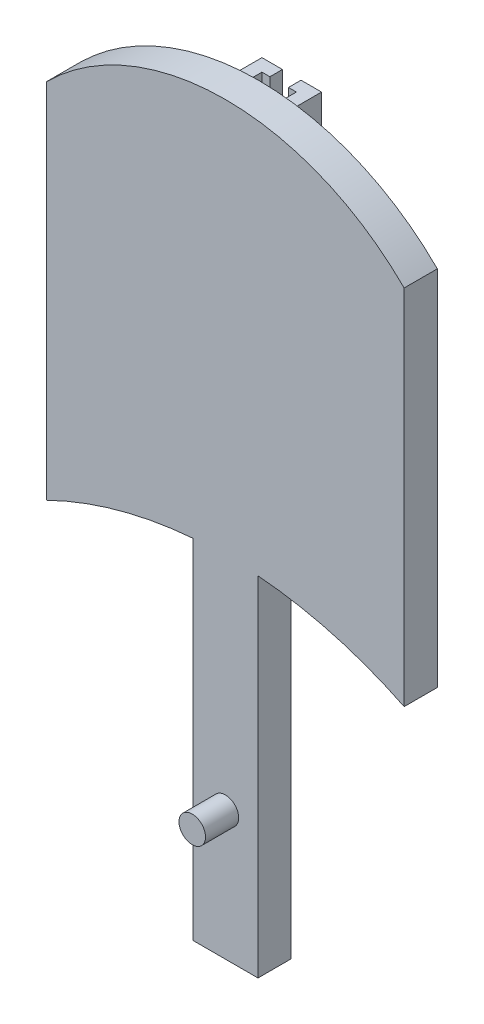
from build123d import *

# Parameters (mm, degrees)
BOSS_EXTRUDE1_DEPTH = 3.175
BOSS_EXTRUDE2_DEPTH = 3.175
SKETCH3_W           = 6.236959702
SKETCH3_H           = 47.194711522
BOSS_EXTRUDE3_DEPTH = 3.175
SKETCH4_R           = 1.27
BOSS_EXTRUDE4_DEPTH = 3.175
BOSS_EXTRUDE5_REACH = 20.766
SKETCH6_W           = 1.202138058
SKETCH6_H           = 36.716281243
CUT_EXTRUDE1_REACH  = 11.525


with BuildPart() as part:
    # Sketch1 → Boss-Extrude1 (new body)
    with BuildSketch(Plane.XY):
        with BuildLine():
            Line((-17.114253333, -17.357583949), (-17.114253333, 17.357583949))
            ThreePointArc((-17.114253333, 17.357583949), (0, 24.432200125), (17.114253333, 17.357583949))
            Line((17.114253333, 17.357583949), (17.114253333, -17.357583949))
            ThreePointArc((17.114253333, -17.357583949), (0, -13.382802691), (-17.114253333, -17.357583949))
        make_face()
    extrude(amount=BOSS_EXTRUDE1_DEPTH)

    # Sketch2 → Boss-Extrude2 (add)
    with BuildSketch(Plane(origin=(0, 0, 0), x_dir=(-1, 0, 0), z_dir=(0, 0, -1))):
        with BuildLine():
            Line((-1.65128862, -13.417928303), (-1.65128862, 22.268343179))
            Line((-1.65128862, 22.268343179), (-1.65128862, 23.29835294))
            Line((-1.65128862, 23.29835294), (-2.853426735, 23.29835294))
            Line((-2.853426735, 23.29835294), (-2.853426735, -13.48778167))
            ThreePointArc((-2.853426735, -13.48778167), (-2.25262846, -13.448194961), (-1.65128862, -13.417928303))
        make_face()
        with BuildLine():
            Line((1.65128862, 23.29835294), (1.65128862, 22.268343179))
            Line((1.65128862, 22.268343179), (1.65128862, -13.417928303))
            ThreePointArc((1.65128862, -13.417928303), (2.25262846, -13.448194961), (2.853426735, -13.48778167))
            Line((2.853426735, -13.48778167), (2.853426735, 23.29835294))
            Line((2.853426735, 23.29835294), (1.65128862, 23.29835294))
        make_face()
    extrude(amount=BOSS_EXTRUDE2_DEPTH)

    # Sketch3 → Boss-Extrude3 (add)
    with BuildSketch(Plane.XY.offset(3.175)):
        with Locations((0, -23.258467244)):
            Rectangle(SKETCH3_W, SKETCH3_H)
    extrude(amount=-BOSS_EXTRUDE3_DEPTH)

    # Sketch4 → Boss-Extrude4 (add)
    with BuildSketch(Plane.XY.offset(3.175)):
        with Locations((0, -34.503683415)):
            Circle(SKETCH4_R)
    extrude(amount=BOSS_EXTRUDE4_DEPTH)

    # Sketch6 → Boss-Extrude5 (add, up to next)
    with BuildSketch(Plane.ZY.offset(-1.65128862), mode=Mode.PRIVATE) as boss_extrude5_sk1:
        with Locations((-2.573930971, 4.940212319)):
            Rectangle(SKETCH6_W, SKETCH6_H)
    boss_extrude5_tool1 = extrude(boss_extrude5_sk1.sketch, amount=BOSS_EXTRUDE5_REACH, mode=Mode.PRIVATE) - part.part
    add(boss_extrude5_tool1.solids().sort_by_distance((1.651289, 4.940212, -2.573931))[0])

    # Sketch8 → Cut-Extrude1 (cut, up to next)
    with BuildSketch(Plane(origin=(0, 0, -3.175), x_dir=(-1, 0, 0), z_dir=(0, 0, -1)), mode=Mode.PRIVATE) as cut_extrude1_sk1:
        Polygon((0, 23.29835294), (-0.889, 23.29835294), (-0.889, -13.417928303), (0.889, -13.417928303), (0.889, 23.29835294), align=None)
    cut_extrude1_tool1 = extrude(cut_extrude1_sk1.sketch, amount=-CUT_EXTRUDE1_REACH, mode=Mode.PRIVATE) & part.part
    add(cut_extrude1_tool1.solids().sort_by_distance((0, 4.940212, -3.175))[0], mode=Mode.SUBTRACT)


solid = part.part
